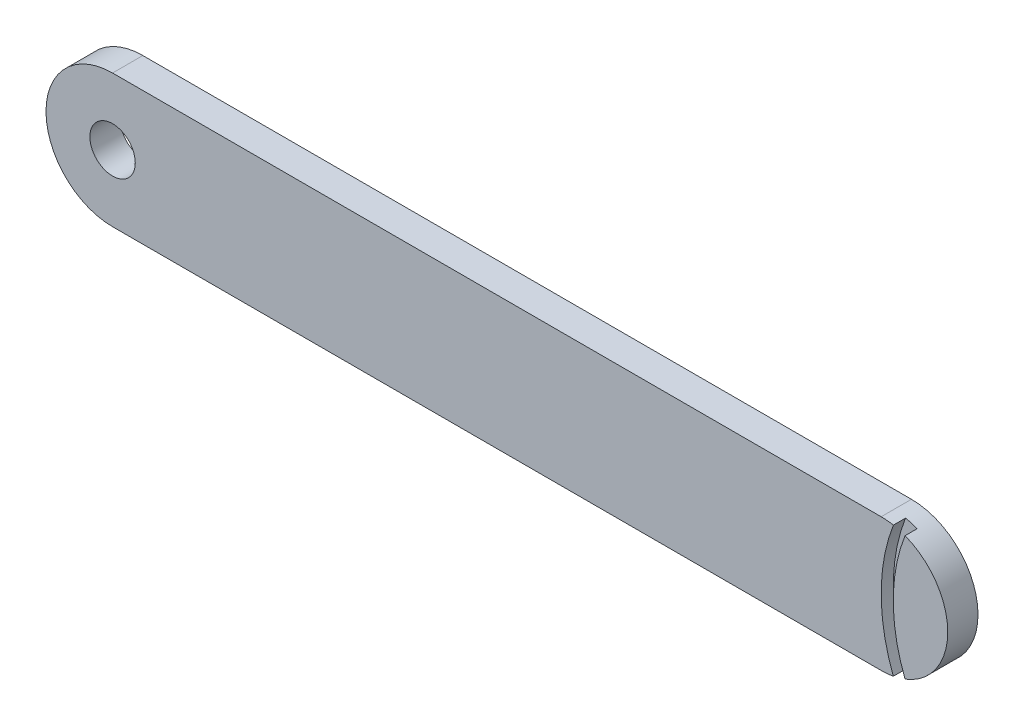
from build123d import *

# Parameters (mm, degrees)
SKETCH1_R           = 3.75
BOSS_EXTRUDE1_DEPTH = 5
CUT_EXTRUDE1_DEPTH  = 2
CUT_EXTRUDE2_DEPTH  = 1.5


with BuildPart() as part:
    # Sketch1 → Boss-Extrude1 (new body)
    with BuildSketch(Plane.XY):
        with BuildLine():
            ThreePointArc((0, 22), (-11, 11), (0, 0))
            Line((0, 0), (127, 0))
            ThreePointArc((127, 0), (138, 11), (127, 22))
            Line((127, 22), (0, 22))
        make_face()
        with Locations((0, 11)):
            Circle(SKETCH1_R, mode=Mode.SUBTRACT)
    extrude(amount=BOSS_EXTRUDE1_DEPTH)

    # Sketch2 → Cut-Extrude1 (cut)
    with BuildSketch(Plane.XY.offset(5)):
        with BuildLine():
            ThreePointArc((129.016666667, 21.813558876), (127, 11), (129.016666667, 0.186441124))
            ThreePointArc((129.016666667, 0.186441124), (129.995854312, 0.415820441), (130.95, 0.733671542))
            ThreePointArc((130.95, 0.733671542), (129, 11), (130.95, 21.266328458))
            ThreePointArc((130.95, 21.266328458), (129.995854312, 21.584179559), (129.016666667, 21.813558876))
        make_face()
    extrude(amount=-CUT_EXTRUDE1_DEPTH, mode=Mode.SUBTRACT)

    # Sketch3 → Cut-Extrude2 (cut)
    with BuildSketch(Plane(origin=(0, 0, 0), x_dir=(-1, 0, 0), z_dir=(0, 0, -1))):
        with BuildLine():
            Line((0, 14.75), (-18.25, 14.75))
            ThreePointArc((-18.25, 14.75), (-22, 11), (-18.25, 7.25))
            Line((-18.25, 7.25), (0, 7.25))
            ThreePointArc((0, 7.25), (-3.75, 11), (0, 14.75))
        make_face()
    extrude(amount=-CUT_EXTRUDE2_DEPTH, mode=Mode.SUBTRACT)


solid = part.part
